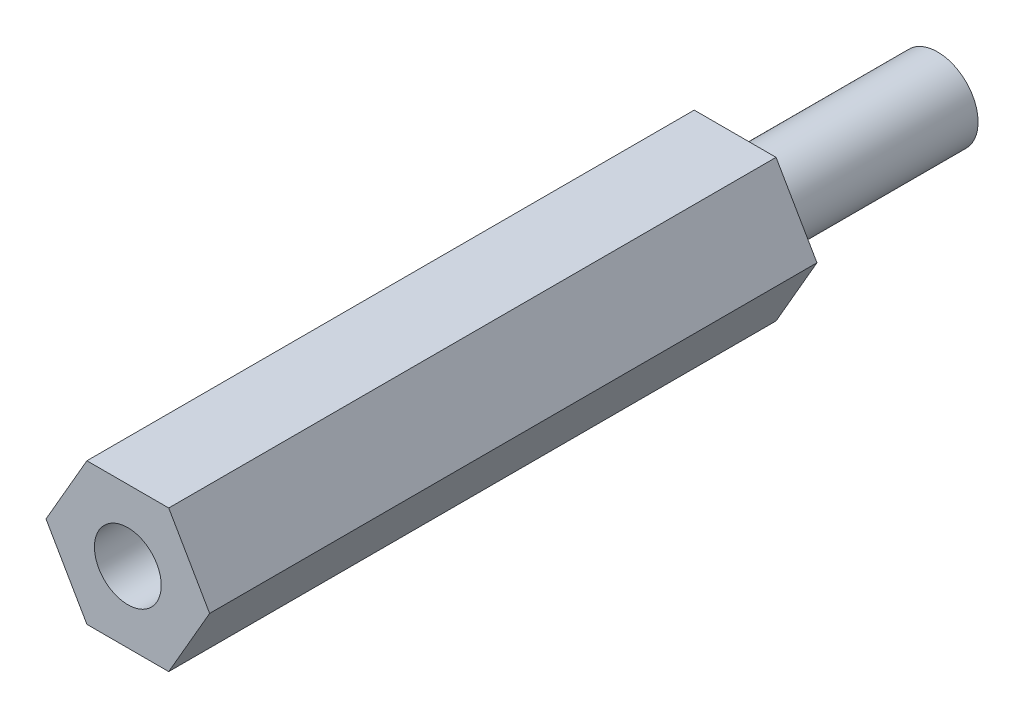
from build123d import *

# Parameters (mm, degrees)
EXTRUDE_1_DEPTH = 30
SKETCH_4_R      = 2
EXTRUDE_2_DEPTH = 10
M4X0_7_1_D      = 3.3
M4X0_7_1_DEPTH  = 10.1
M4X0_7_1_TIP    = 0.991420021


with BuildPart() as part:
    # 草圖1 → 填料-伸長1 (new body)
    with BuildSketch(Plane.XY):
        Polygon((-2.020725942, 3.5), (-4.041451884, 0), (-2.020725942, -3.5), (2.020725942, -3.5), (4.041451884, 0), (2.020725942, 3.5), align=None)
    extrude(amount=EXTRUDE_1_DEPTH)

    # 草圖4 → 填料-伸長2 (add)
    with BuildSketch(Plane(origin=(0, 0, 0), x_dir=(-1, 0, 0), z_dir=(0, 0, -1))):
        Circle(SKETCH_4_R)
    extrude(amount=EXTRUDE_2_DEPTH)

    # M4x0.7 螺紋孔1
    with Locations(Plane.XY.offset(30)):
        with Locations((0, 0)):
            Hole(M4X0_7_1_D / 2, depth=M4X0_7_1_DEPTH)
            with Locations((0, 0, -(M4X0_7_1_DEPTH + M4X0_7_1_TIP / 2))):  # 118° drill point
                Cone(0, M4X0_7_1_D / 2, M4X0_7_1_TIP, mode=Mode.SUBTRACT)


solid = part.part
